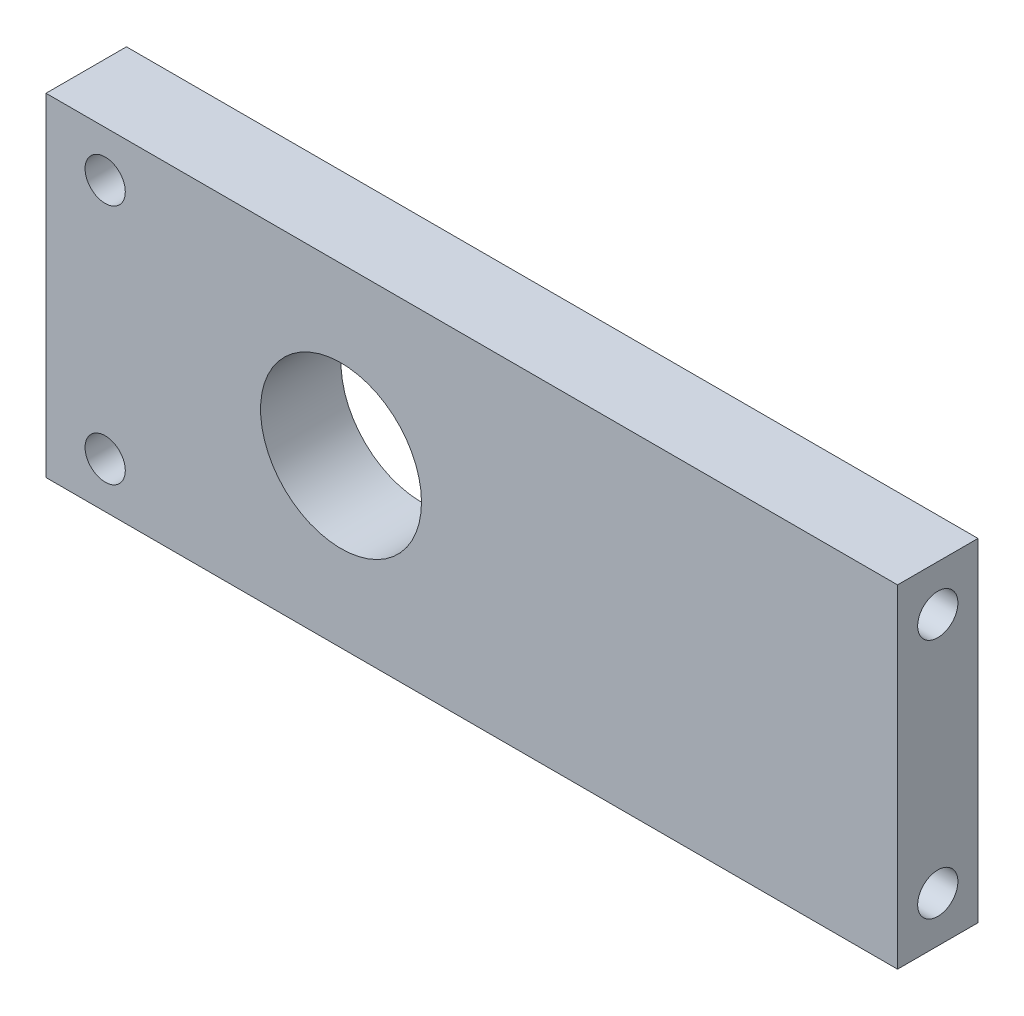
from build123d import *

# Parameters (mm, degrees)
ESQUISSE1_W             = 63.5
ESQUISSE1_H             = 24.82
ESQUISSE1_R             = 6
BOSS_EXTRU_1_DEPTH      = 6
ESQUISSE2_R             = 1.5
ENL_V_MAT_EXTRU_1_DEPTH = 10
ESQUISSE3_R             = 1.5
ENL_V_MAT_EXTRU_2_DEPTH = 10


with BuildPart() as part:
    # Esquisse1 → Boss.-Extru.1 (new body)
    with BuildSketch(Plane.XY):
        with Locations((13.304900678, -1.402259887)):
            Rectangle(ESQUISSE1_W, ESQUISSE1_H)
        with Locations((3.554900678, -1.402259887)):
            Circle(ESQUISSE1_R, mode=Mode.SUBTRACT)
    extrude(amount=BOSS_EXTRU_1_DEPTH)

    # Esquisse2 → Enlèv. mat.-Extru.1 (cut)
    with BuildSketch(Plane(origin=(45.054900678, 0, 0), x_dir=(0, 0, -1), z_dir=(1, 0, 0))):
        with Locations((-3, 7.597740113)):
            Circle(ESQUISSE2_R)
        with Locations((-3, -10.402259887)):
            Circle(ESQUISSE2_R)
    extrude(amount=-ENL_V_MAT_EXTRU_1_DEPTH, mode=Mode.SUBTRACT)

    # Esquisse3 → Enlèv. mat.-Extru.2 (cut)
    with BuildSketch(Plane(origin=(0, 0, 0), x_dir=(-1, 0, 0), z_dir=(0, 0, -1))):
        with Locations((14.031893584, 7.597740113)):
            Circle(ESQUISSE3_R)
        with Locations((14.031893584, -10.402259887)):
            Circle(ESQUISSE3_R)
    extrude(amount=-ENL_V_MAT_EXTRU_2_DEPTH, mode=Mode.SUBTRACT)


solid = part.part
